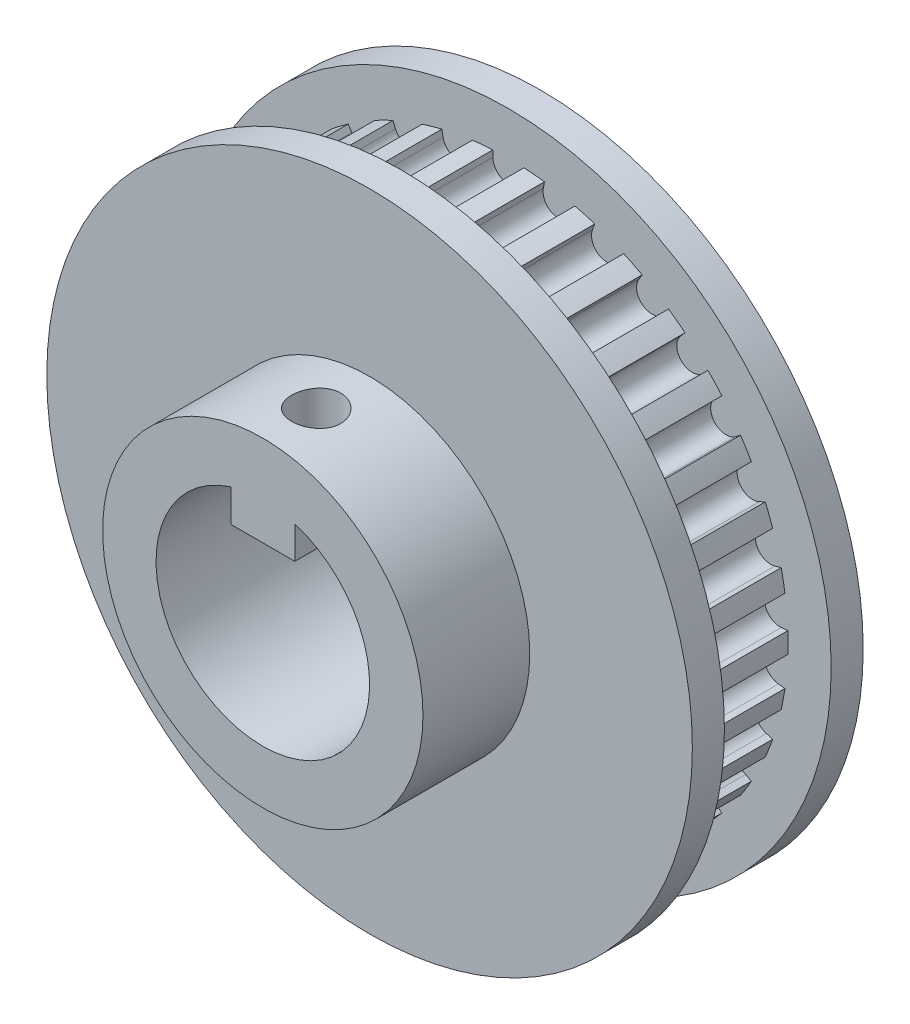
from build123d import *

# Parameters (mm, degrees)
CUT_EXTRUDE1_DEPTH  = 10
CIRPATTERN1_COUNT   = 34
SKETCH5_W           = 6
SKETCH5_H           = 3.5
BOSS_EXTRUDE1_DEPTH = 26
SKETCH4_R           = 2.3
CUT_EXTRUDE2_DEPTH  = 10


with BuildPart() as part:
    # Sketch2 → Revolve1 (revolve)
    with BuildSketch(Plane(origin=(0, 0, 0), x_dir=(0, 0, -1), z_dir=(1, 0, 0)), mode=Mode.PRIVATE) as revolve1_sk:
        Polygon((-13, 10), (13, 10), (13, 30.23), (10, 30.23), (10, 26.1874), (0, 26.1874), (0, 28.2087), (0, 30.23), (-1.5, 30.23), (-3, 30.23), (-3, 15), (-13, 15), align=None)
    revolve(revolve1_sk.sketch.rotate(Axis((0, 0, 13), (0, 0, -1)), 90), axis=Axis((0, 0, 13), (0, 0, -1)))

    # Sketch3 → Cut-Extrude1 (cut)
    with BuildSketch(Plane.XY):
        with BuildLine():
            Line((-1.447918132, 25.537202459), (-1.45440268, 26.14698131))
            ThreePointArc((-1.45440268, 26.14698131), (0, 26.1874), (1.45440268, 26.14698131))
            Line((1.45440268, 26.14698131), (1.447918132, 25.537202459))
            ThreePointArc((1.447918132, 25.537202459), (0, 24.1046), (-1.447918132, 25.537202459))
        make_face()
    cut_extrude1 = extrude(amount=-CUT_EXTRUDE1_DEPTH, mode=Mode.SUBTRACT)

    # CirPattern1: Cut-Extrude1 ×34 about axis
    cirpattern1_axis = Axis((0, 0, 0), (0, 0, 1))
    for i in range(1, CIRPATTERN1_COUNT):
        add(cut_extrude1.rotate(cirpattern1_axis, i * 360 / CIRPATTERN1_COUNT), mode=Mode.SUBTRACT)

    # Sketch5 → Boss-Extrude1 (add)
    with BuildSketch(Plane.XY.offset(13)):
        with Locations((0, 8.25)):
            Rectangle(SKETCH5_W, SKETCH5_H)
    extrude(amount=-BOSS_EXTRUDE1_DEPTH)

    # Sketch4 → Cut-Extrude2 (cut)
    with BuildSketch(Plane(origin=(0, 15, 0), x_dir=(1, 0, 0), z_dir=(0, 1, 0))):
        with Locations(Location((0, -8, 0), (0, 0, 270))):
            Circle(SKETCH4_R)
    extrude(amount=-CUT_EXTRUDE2_DEPTH, mode=Mode.SUBTRACT)


solid = part.part
